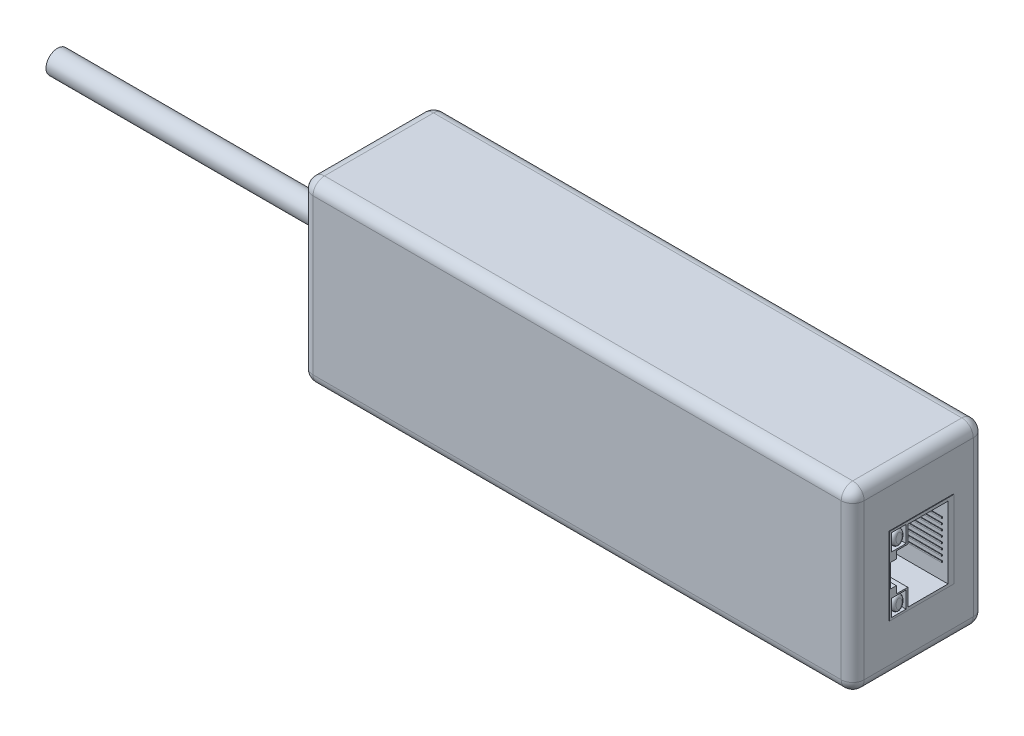
from build123d import *

# Parameters (mm, degrees)
SKETCH_1_W             = 96
SKETCH_1_H             = 31
EXTRUDE_1_DEPTH        = 11.5
SKETCH_2_W             = 5.5
SKETCH_2_H             = 14
CUT_EXTRUDE_1_DEPTH    = 10
CUT_EXTRUDE_2_DEPTH    = 12
SKETCH_4_R             = 3
EXTRUDE_2_DEPTH        = 4
FILLET_1_R             = 2
SKETCH_5_R             = 2
EXTRUDE_3_DEPTH        = 50
SKETCH_6_W             = 1.5
SKETCH_6_H             = 13
EXTRUDE_4_DEPTH        = 10
EXTRUDE_START          = -0.5
SKETCH_7_W             = 7.5
SKETCH_7_H             = 1.8
SKETCH_7_W_2           = 6
SKETCH_7_H_2           = 1.5
EXTRUDE_5_DEPTH        = 0.6
PATTERN_LINEAR_1_COUNT = 3
PATTERN_LINEAR_1_PITCH = 17
SKETCH_8_W             = 11.2
SKETCH_8_H             = 13.5
EXTRUDE_6_DEPTH        = 0.1
EXTRUDE_6_DEPTH_BACK   = 0.1
SKETCH_9_W             = 2.5
SKETCH_9_H             = 2.9
CUT_EXTRUDE_3_DEPTH    = 5
SKETCH_10_RX           = 1.35
SKETCH_10_RY           = 1
EXTRUDE_9_DEPTH        = 5
FILLET_2_R             = 0.5
FILLET_2_OF_MIRROR_1_R = 0.5
SKETCH_11_W            = 10
SKETCH_11_H            = 0.25
EXTRUDE_10_DEPTH       = 0.1
PATTERN_LINEAR_2_COUNT = 8
PATTERN_LINEAR_2_PITCH = 0.95


with BuildPart() as part:
    # 草圖1 → 填料-伸長1 (new, symmetric)
    with BuildSketch(Plane.XY):
        Rectangle(SKETCH_1_W, SKETCH_1_H)
    extrude(amount=EXTRUDE_1_DEPTH, both=True)

    # 草圖2 → 除料-伸長1 (cut)
    with BuildSketch(Plane(origin=(0, 0, -11.5), x_dir=(-1, 0, 0), z_dir=(0, 0, -1))):
        with Locations((20.25, 0)):
            Rectangle(SKETCH_2_W, SKETCH_2_H)
        with Locations((3.25, 0)):
            Rectangle(SKETCH_2_W, SKETCH_2_H)
        with Locations((-13.75, 0)):
            Rectangle(SKETCH_2_W, SKETCH_2_H)
    extrude(amount=-CUT_EXTRUDE_1_DEPTH, mode=Mode.SUBTRACT)

    # 草圖3 → 除料-伸長2 (cut)
    with BuildSketch(Plane(origin=(48, 0, 0), x_dir=(0, 0, -1), z_dir=(1, 0, 0))):
        Polygon((5, 6.25), (5, -6.25), (-2, -6.25), (-2, -3.25), (-4, -3.25), (-4, -2), (-5, -2), (-5, 2), (-4, 2), (-4, 3.25), (-2, 3.25), (-2, 6.25), align=None)
    extrude(amount=-CUT_EXTRUDE_2_DEPTH, mode=Mode.SUBTRACT)

    # 草圖4 → 填料-伸長2 (add)
    with BuildSketch(Plane.ZY.offset(48)):
        with Locations(Location((0, 0, 0), (0, 0, 270))):
            Circle(SKETCH_4_R)
    extrude(amount=EXTRUDE_2_DEPTH)

    # 圓角1
    fillet_1_edges = [part.edges().sort_by_distance(p)[0] for p in [
        (-48, 0, 11.5),
        (0, -15.5, 11.5),
        (48, 0, 11.5),
        (0, -15.5, -11.5),
        (-48, 0, -11.5),
        (0, 15.5, -11.5),
        (48, 0, -11.5),
        (0, 15.5, 11.5),
        (48, -15.5, 0),
        (-48, -15.5, 0),
        (-48, 15.5, 0),
        (48, 15.5, 0),
    ]]
    fillet(fillet_1_edges, radius=FILLET_1_R)


with BuildPart() as body_2:
    # Split Bodies 1: the piece on the far side of the plane
    add(part.part)
    split(bisect_by=Plane.XY, keep=Keep.BOTTOM)


with BuildPart() as part_1:
    add(part.part)

    # Split Bodies 1
    split(bisect_by=Plane.XY, keep=Keep.TOP)

    add(body_2.part)  # 填料-伸長3 merges body 2
    # 草圖5 → 填料-伸長3 (add)
    with BuildSketch(Plane.ZY.offset(52)):
        with Locations(Location((0, 0, 0), (0, 0, 270))):
            Circle(SKETCH_5_R)
    extrude(amount=EXTRUDE_3_DEPTH)

    # 草圖6 → 填料-伸長4 (add)
    with BuildSketch(Plane(origin=(0, 0, -1.5), x_dir=(-1, 0, 0), z_dir=(0, 0, -1))):
        with Locations((19.25, 0)):
            Rectangle(SKETCH_6_W, SKETCH_6_H)
    extrude_4 = extrude(amount=EXTRUDE_4_DEPTH)

    # 草圖7 → 填料-伸長5 (add)
    with BuildSketch(Plane.ZY.offset(20).offset(EXTRUDE_START)):
        with Locations((-6.75, 4.65)):
            Rectangle(SKETCH_7_W, SKETCH_7_H)
        with Locations((-7.5, 1.5)):
            Rectangle(SKETCH_7_W_2, SKETCH_7_H_2)
        with Locations((-7.5, -1.5)):
            Rectangle(SKETCH_7_W_2, SKETCH_7_H_2)
        with Locations((-6.75, -4.65)):
            Rectangle(SKETCH_7_W, SKETCH_7_H)
    extrude_5 = extrude(amount=EXTRUDE_5_DEPTH)

    # 直線複製排列1: 填料-伸長4, 填料-伸長5 ×3
    with Locations(*[(i * PATTERN_LINEAR_1_PITCH, 0, 0) for i in range(1, PATTERN_LINEAR_1_COUNT)]):
        add(extrude_4)
        add(extrude_5)

    # 草圖8 → 填料-伸長6 (add, two sides)
    with BuildSketch(Plane(origin=(48, 0, 0), x_dir=(0, 0, -1), z_dir=(1, 0, 0))) as extrude_6_sk:
        with Locations((0.4, 0)):
            Rectangle(SKETCH_8_W, SKETCH_8_H)
        Polygon((-2, 6.25), (5, 6.25), (5, -6.25), (-2, -6.25), (-2, -3.25), (-4, -3.25), (-4, -2), (-5, -2), (-5, 2), (-4, 2), (-4, 3.25), (-2, 3.25), align=None, mode=Mode.SUBTRACT)
    extrude(amount=EXTRUDE_6_DEPTH)
    extrude(extrude_6_sk.sketch, amount=-EXTRUDE_6_DEPTH_BACK)

    # 草圖9 → 除料-伸長3 (cut)
    with BuildSketch(Plane(origin=(48.1, 0, 0), x_dir=(0, 0, -1), z_dir=(1, 0, 0))):
        with Locations((-3.55, 4.946278338)):
            Rectangle(SKETCH_9_W, SKETCH_9_H)
        with Locations((-3.55, -4.946278338)):
            Rectangle(SKETCH_9_W, SKETCH_9_H)
    extrude(amount=-CUT_EXTRUDE_3_DEPTH, mode=Mode.SUBTRACT)

    # 草圖10 → 填料-伸長9 (add)
    with BuildSketch(Plane(origin=(43.1, 0, 0), x_dir=(0, 0, -1), z_dir=(1, 0, 0))):
        with Locations(Location((-3.55, 4.946278338), (0, 0, -90))):
            Ellipse(SKETCH_10_RX, SKETCH_10_RY)
    extrude_9 = extrude(amount=EXTRUDE_9_DEPTH)

    # 圓角2
    fillet_2_edges = [part_1.edges().sort_by_distance(p)[0] for p in [
        (48.1, 6.296278229, 3.550400835),
    ]]
    fillet(fillet_2_edges, radius=FILLET_2_R)

    # 鏡射1: 填料-伸長9 across plane
    add(extrude_9.mirror(Plane.ZX))

    # 圓角2 of 鏡射1
    fillet_2_of_mirror_1_edges = [part_1.edges().sort_by_distance(p)[0] for p in [
        (48.1, -6.296278229, 3.550400835),
    ]]
    fillet(fillet_2_of_mirror_1_edges, radius=FILLET_2_OF_MIRROR_1_R)

    # 草圖11 → 填料-伸長10 (add)
    with BuildSketch(Plane.XY.offset(-5)):
        with Locations((42.1, -3.375)):
            Rectangle(SKETCH_11_W, SKETCH_11_H)
    extrude_10 = extrude(amount=EXTRUDE_10_DEPTH)

    # 直線複製排列2: 填料-伸長10 ×8
    with Locations(*[(0, i * PATTERN_LINEAR_2_PITCH, 0) for i in range(1, PATTERN_LINEAR_2_COUNT)]):
        add(extrude_10)


solid = part_1.part
